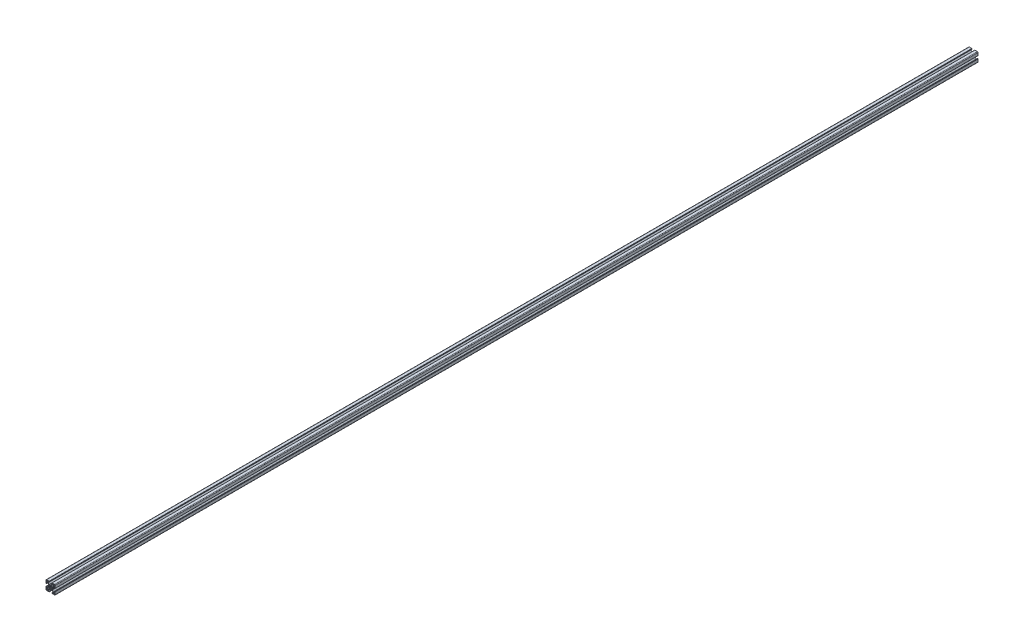
from build123d import *

# Parameters (mm, degrees)
SIGMA_PROFILE_DEPTH = 3000


with BuildPart() as part:
    # Sketch1 → Sigma Profile (new body)
    with BuildSketch(Plane.XY):
        with BuildLine():
            Line((96.56, 29.575148163), (97.459999946, 29.06))
            Line((97.459999946, 29.06), (100.764466193, 29.06))
            Line((100.764466193, 29.06), (104.810000327, 25.010000763))
            Line((104.810000327, 25.010000763), (104.810000327, 22.460001166))
            ThreePointArc((104.810000327, 22.460001166), (104.751421565, 22.318579525), (104.609999924, 22.260000763))
            Line((104.609999924, 22.260000763), (101.210000197, 22.260000763))
            ThreePointArc((101.210000197, 22.260000763), (100.785735989, 22.084264774), (100.61, 21.660000566))
            Line((100.61, 21.660000566), (100.61, 20.760000374))
            ThreePointArc((100.61, 20.760000374), (100.668578753, 20.618578753), (100.810000374, 20.56))
            Line((100.810000374, 20.56), (100.910000144, 20.56))
            ThreePointArc((100.910000144, 20.56), (101.05142109, 20.501421526), (101.109999564, 20.36000058))
            Line((101.109999564, 20.36000058), (101.109999564, 20.260000381))
            ThreePointArc((101.109999564, 20.260000381), (101.16857832, 20.118578755), (101.309999945, 20.06))
            Line((101.309999945, 20.06), (109.560000346, 20.06))
            ThreePointArc((109.560000346, 20.06), (110.974213664, 20.645786336), (111.56, 22.059999654))
            Line((111.56, 22.059999654), (111.56, 30.310000479))
            ThreePointArc((111.56, 30.310000479), (111.501421273, 30.451422036), (111.359999716, 30.510000763))
            Line((111.359999716, 30.510000763), (111.260000611, 30.510000763))
            ThreePointArc((111.260000611, 30.510000763), (111.118579054, 30.56857949), (111.060000327, 30.710001047))
            Line((111.060000327, 30.710001047), (111.060000327, 30.810000479))
            ThreePointArc((111.060000327, 30.810000479), (111.0014216, 30.951422036), (110.860000043, 31.010000763))
            Line((110.860000043, 31.010000763), (109.95999994, 31.010000763))
            ThreePointArc((109.95999994, 31.010000763), (109.535735606, 30.834264722), (109.359999564, 30.410000387))
            Line((109.359999564, 30.410000387), (109.359999564, 27.010000284))
            ThreePointArc((109.359999564, 27.010000284), (109.301420837, 26.868578727), (109.15999928, 26.81))
            Line((109.15999928, 26.81), (106.609999564, 26.81))
            Line((106.609999564, 26.81), (102.56446543, 30.855534134))
            Line((102.56446543, 30.855534134), (102.56446543, 34.160000381))
            Line((102.56446543, 34.160000381), (102.044852164, 35.06))
            Line((102.044852164, 35.06), (102.56446543, 35.959999619))
            Line((102.56446543, 35.959999619), (102.56446543, 39.264465866))
            Line((102.56446543, 39.264465866), (106.609999564, 43.31))
            Line((106.609999564, 43.31), (109.15999928, 43.31))
            ThreePointArc((109.15999928, 43.31), (109.301420837, 43.251421273), (109.359999564, 43.109999716))
            Line((109.359999564, 43.109999716), (109.359999564, 39.709999613))
            ThreePointArc((109.359999564, 39.709999613), (109.535735606, 39.285735278), (109.95999994, 39.109999237))
            Line((109.95999994, 39.109999237), (110.860000043, 39.109999237))
            ThreePointArc((110.860000043, 39.109999237), (111.0014216, 39.168577964), (111.060000327, 39.309999521))
            Line((111.060000327, 39.309999521), (111.060000327, 39.409998953))
            ThreePointArc((111.060000327, 39.409998953), (111.118579054, 39.55142051), (111.260000611, 39.609999237))
            Line((111.260000611, 39.609999237), (111.359999716, 39.609999237))
            ThreePointArc((111.359999716, 39.609999237), (111.501421273, 39.668577964), (111.56, 39.809999521))
            Line((111.56, 39.809999521), (111.56, 48.060000346))
            ThreePointArc((111.56, 48.060000346), (110.974213664, 49.474213664), (109.560000346, 50.06))
            Line((109.560000346, 50.06), (101.309999945, 50.06))
            ThreePointArc((101.309999945, 50.06), (101.16857832, 50.001421245), (101.109999564, 49.859999619))
            Line((101.109999564, 49.859999619), (101.109999564, 49.75999942))
            ThreePointArc((101.109999564, 49.75999942), (101.05142109, 49.618578474), (100.910000144, 49.56))
            Line((100.910000144, 49.56), (100.810000374, 49.56))
            ThreePointArc((100.810000374, 49.56), (100.668578753, 49.501421247), (100.61, 49.359999626))
            Line((100.61, 49.359999626), (100.61, 48.459999434))
            ThreePointArc((100.61, 48.459999434), (100.785735989, 48.035735226), (101.210000197, 47.859999237))
            Line((101.210000197, 47.859999237), (104.609999924, 47.859999237))
            ThreePointArc((104.609999924, 47.859999237), (104.751421565, 47.801420475), (104.810000327, 47.659998834))
            Line((104.810000327, 47.659998834), (104.810000327, 45.109999237))
            Line((104.810000327, 45.109999237), (100.764466193, 41.06))
            Line((100.764466193, 41.06), (97.459999946, 41.06))
            Line((97.459999946, 41.06), (96.56, 40.544851837))
            Line((96.56, 40.544851837), (95.660000054, 41.06))
            Line((95.660000054, 41.06), (92.355533807, 41.06))
            Line((92.355533807, 41.06), (88.309999673, 45.109999237))
            Line((88.309999673, 45.109999237), (88.309999673, 47.659998834))
            ThreePointArc((88.309999673, 47.659998834), (88.368578435, 47.801420475), (88.510000076, 47.859999237))
            Line((88.510000076, 47.859999237), (91.909999803, 47.859999237))
            ThreePointArc((91.909999803, 47.859999237), (92.334264011, 48.035735226), (92.51, 48.459999434))
            Line((92.51, 48.459999434), (92.51, 49.359999626))
            ThreePointArc((92.51, 49.359999626), (92.451421247, 49.501421247), (92.309999626, 49.56))
            Line((92.309999626, 49.56), (92.209999856, 49.56))
            ThreePointArc((92.209999856, 49.56), (92.06857891, 49.618578474), (92.010000436, 49.75999942))
            Line((92.010000436, 49.75999942), (92.010000436, 49.859999619))
            ThreePointArc((92.010000436, 49.859999619), (91.95142168, 50.001421245), (91.810000055, 50.06))
            Line((91.810000055, 50.06), (83.559999654, 50.06))
            ThreePointArc((83.559999654, 50.06), (82.145786336, 49.474213664), (81.56, 48.060000346))
            Line((81.56, 48.060000346), (81.56, 39.809999521))
            ThreePointArc((81.56, 39.809999521), (81.618578727, 39.668577964), (81.760000284, 39.609999237))
            Line((81.760000284, 39.609999237), (81.859999389, 39.609999237))
            ThreePointArc((81.859999389, 39.609999237), (82.001420946, 39.55142051), (82.059999673, 39.409998953))
            Line((82.059999673, 39.409998953), (82.059999673, 39.309999521))
            ThreePointArc((82.059999673, 39.309999521), (82.1185784, 39.168577964), (82.259999957, 39.109999237))
            Line((82.259999957, 39.109999237), (83.16000006, 39.109999237))
            ThreePointArc((83.16000006, 39.109999237), (83.584264394, 39.285735278), (83.760000436, 39.709999613))
            Line((83.760000436, 39.709999613), (83.760000436, 43.109999716))
            ThreePointArc((83.760000436, 43.109999716), (83.818579163, 43.251421273), (83.96000072, 43.31))
            Line((83.96000072, 43.31), (86.510000436, 43.31))
            Line((86.510000436, 43.31), (90.55553457, 39.264465866))
            Line((90.55553457, 39.264465866), (90.55553457, 35.959999619))
            Line((90.55553457, 35.959999619), (91.075147836, 35.06))
            Line((91.075147836, 35.06), (90.55553457, 34.160000381))
            Line((90.55553457, 34.160000381), (90.55553457, 30.855534134))
            Line((90.55553457, 30.855534134), (86.510000436, 26.81))
            Line((86.510000436, 26.81), (83.96000072, 26.81))
            ThreePointArc((83.96000072, 26.81), (83.818579163, 26.868578727), (83.760000436, 27.010000284))
            Line((83.760000436, 27.010000284), (83.760000436, 30.410000387))
            ThreePointArc((83.760000436, 30.410000387), (83.584264394, 30.834264722), (83.16000006, 31.010000763))
            Line((83.16000006, 31.010000763), (82.259999957, 31.010000763))
            ThreePointArc((82.259999957, 31.010000763), (82.1185784, 30.951422036), (82.059999673, 30.810000479))
            Line((82.059999673, 30.810000479), (82.059999673, 30.710001047))
            ThreePointArc((82.059999673, 30.710001047), (82.001420946, 30.56857949), (81.859999389, 30.510000763))
            Line((81.859999389, 30.510000763), (81.760000284, 30.510000763))
            ThreePointArc((81.760000284, 30.510000763), (81.618578727, 30.451422036), (81.56, 30.310000479))
            Line((81.56, 30.310000479), (81.56, 22.059999654))
            ThreePointArc((81.56, 22.059999654), (82.145786336, 20.645786336), (83.559999654, 20.06))
            Line((83.559999654, 20.06), (91.810000055, 20.06))
            ThreePointArc((91.810000055, 20.06), (91.95142168, 20.118578755), (92.010000436, 20.260000381))
            Line((92.010000436, 20.260000381), (92.010000436, 20.36000058))
            ThreePointArc((92.010000436, 20.36000058), (92.06857891, 20.501421526), (92.209999856, 20.56))
            Line((92.209999856, 20.56), (92.309999626, 20.56))
            ThreePointArc((92.309999626, 20.56), (92.451421247, 20.618578753), (92.51, 20.760000374))
            Line((92.51, 20.760000374), (92.51, 21.660000566))
            ThreePointArc((92.51, 21.660000566), (92.334264011, 22.084264774), (91.909999803, 22.260000763))
            Line((91.909999803, 22.260000763), (88.510000076, 22.260000763))
            ThreePointArc((88.510000076, 22.260000763), (88.368578435, 22.318579525), (88.309999673, 22.460001166))
            Line((88.309999673, 22.460001166), (88.309999673, 25.010000763))
            Line((88.309999673, 25.010000763), (92.355533807, 29.06))
            Line((92.355533807, 29.06), (95.660000054, 29.06))
            Line((95.660000054, 29.06), (96.56, 29.575148163))
        make_face()
        with BuildLine():
            Line((109.26000109, 48.760000398), (107.060000327, 48.760000398))
            ThreePointArc((107.060000327, 48.760000398), (106.352893543, 48.467107182), (106.060000327, 47.760000398))
            Line((106.060000327, 47.760000398), (106.060000327, 45.559999635))
            ThreePointArc((106.060000327, 45.559999635), (106.352893543, 44.852892851), (107.060000327, 44.559999635))
            Line((107.060000327, 44.559999635), (109.26000109, 44.559999635))
            ThreePointArc((109.26000109, 44.559999635), (109.967107874, 44.852892851), (110.26000109, 45.559999635))
            Line((110.26000109, 45.559999635), (110.26000109, 47.760000398))
            ThreePointArc((110.26000109, 47.760000398), (109.967107874, 48.467107182), (109.26000109, 48.760000398))
        make_face(mode=Mode.SUBTRACT)
        with BuildLine():
            Line((94.959870476, 38.340561767), (93.424070588, 39.578400903))
            ThreePointArc((93.424070588, 39.578400903), (92.678997741, 38.957155561), (92.054663108, 38.214669473))
            Line((92.054663108, 38.214669473), (93.279438268, 36.660129597))
            ThreePointArc((93.279438268, 36.660129597), (92.91, 35.06), (93.279438268, 33.459870403))
            Line((93.279438268, 33.459870403), (92.054663108, 31.905330527))
            ThreePointArc((92.054663108, 31.905330527), (92.678997741, 31.162844439), (93.424070588, 30.541599097))
            Line((93.424070588, 30.541599097), (94.959870476, 31.779438233))
            ThreePointArc((94.959870476, 31.779438233), (96.56, 31.41), (98.160129524, 31.779438233))
            Line((98.160129524, 31.779438233), (99.695929412, 30.541599097))
            ThreePointArc((99.695929412, 30.541599097), (100.441002259, 31.162844439), (101.065336892, 31.905330527))
            Line((101.065336892, 31.905330527), (99.840561732, 33.459870403))
            ThreePointArc((99.840561732, 33.459870403), (100.21, 35.06), (99.840561732, 36.660129597))
            Line((99.840561732, 36.660129597), (101.065336892, 38.214669473))
            ThreePointArc((101.065336892, 38.214669473), (100.441002259, 38.957155561), (99.695929412, 39.578400903))
            Line((99.695929412, 39.578400903), (98.160129524, 38.340561767))
            ThreePointArc((98.160129524, 38.340561767), (96.56, 38.71), (94.959870476, 38.340561767))
        make_face(mode=Mode.SUBTRACT)
        with BuildLine():
            Line((83.85999891, 21.359999602), (86.059999673, 21.359999602))
            ThreePointArc((86.059999673, 21.359999602), (86.767106457, 21.652892818), (87.059999673, 22.359999602))
            Line((87.059999673, 22.359999602), (87.059999673, 24.560000365))
            ThreePointArc((87.059999673, 24.560000365), (86.767106457, 25.267107149), (86.059999673, 25.560000365))
            Line((86.059999673, 25.560000365), (83.85999891, 25.560000365))
            ThreePointArc((83.85999891, 25.560000365), (83.152892126, 25.267107149), (82.85999891, 24.560000365))
            Line((82.85999891, 24.560000365), (82.85999891, 22.359999602))
            ThreePointArc((82.85999891, 22.359999602), (83.152892126, 21.652892818), (83.85999891, 21.359999602))
        make_face(mode=Mode.SUBTRACT)
        with BuildLine():
            Line((110.26000109, 22.359999602), (110.26000109, 24.560000365))
            ThreePointArc((110.26000109, 24.560000365), (109.967107874, 25.267107149), (109.26000109, 25.560000365))
            Line((109.26000109, 25.560000365), (107.060000327, 25.560000365))
            ThreePointArc((107.060000327, 25.560000365), (106.352893543, 25.267107149), (106.060000327, 24.560000365))
            Line((106.060000327, 24.560000365), (106.060000327, 22.359999602))
            ThreePointArc((106.060000327, 22.359999602), (106.352893543, 21.652892818), (107.060000327, 21.359999602))
            Line((107.060000327, 21.359999602), (109.26000109, 21.359999602))
            ThreePointArc((109.26000109, 21.359999602), (109.967107874, 21.652892818), (110.26000109, 22.359999602))
        make_face(mode=Mode.SUBTRACT)
        with BuildLine():
            Line((86.059999673, 48.760000398), (83.85999891, 48.760000398))
            ThreePointArc((83.85999891, 48.760000398), (83.152892126, 48.467107182), (82.85999891, 47.760000398))
            Line((82.85999891, 47.760000398), (82.85999891, 45.559999635))
            ThreePointArc((82.85999891, 45.559999635), (83.152892126, 44.852892851), (83.85999891, 44.559999635))
            Line((83.85999891, 44.559999635), (86.059999673, 44.559999635))
            ThreePointArc((86.059999673, 44.559999635), (86.767106457, 44.852892851), (87.059999673, 45.559999635))
            Line((87.059999673, 45.559999635), (87.059999673, 47.760000398))
            ThreePointArc((87.059999673, 47.760000398), (86.767106457, 48.467107182), (86.059999673, 48.760000398))
        make_face(mode=Mode.SUBTRACT)
    extrude(amount=SIGMA_PROFILE_DEPTH)


solid = part.part
